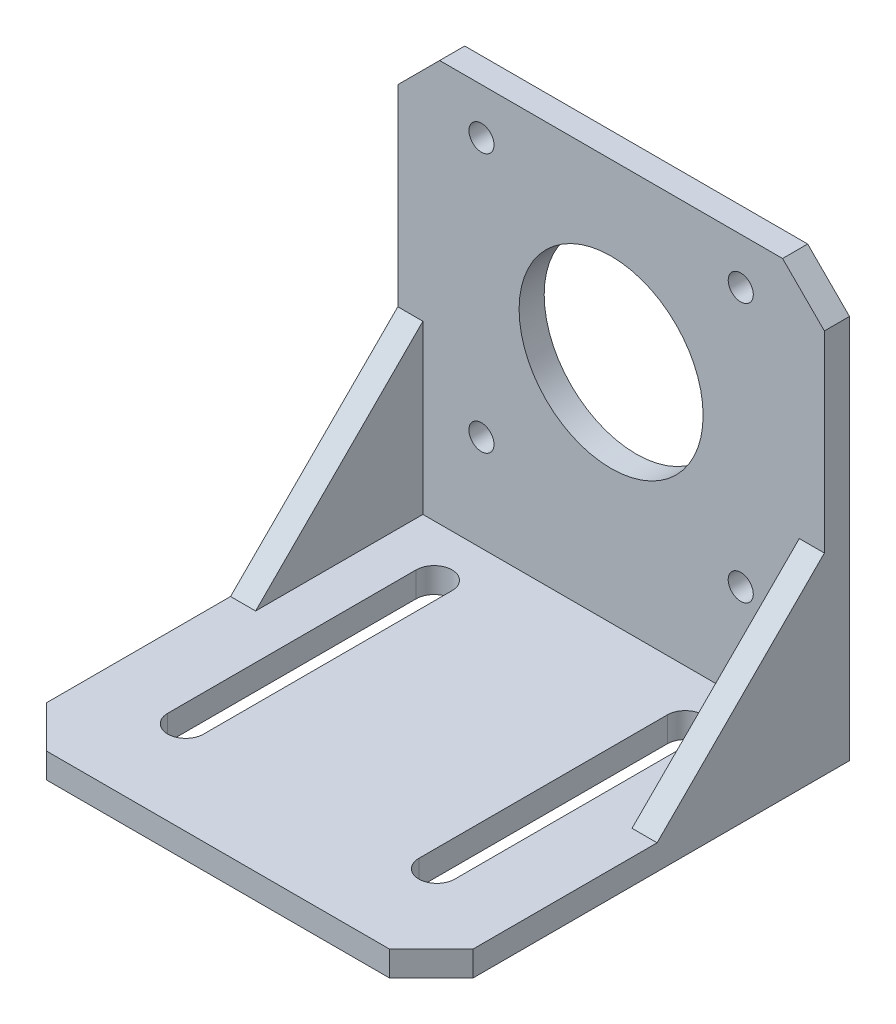
from build123d import *

# Parameters (mm, degrees)
SKETCH1_W           = 51
SKETCH1_H           = 50
BOSS_EXTRUDE1_DEPTH = 3
SKETCH2_W           = 51
SKETCH2_H           = 3
BOSS_EXTRUDE2_DEPTH = 51
SKETCH3_R           = 11
SKETCH3_R_2         = 1.5
CUT_EXTRUDE1_DEPTH  = 4
BOSS_EXTRUDE3_DEPTH = 3
CHAMFER1_SIZE       = 5


with BuildPart() as part:
    # Sketch1 → Boss-Extrude1 (new body)
    with BuildSketch(Plane(origin=(0, 0, 0), x_dir=(1, 0, 0), z_dir=(0, 1, 0))):
        Rectangle(SKETCH1_W, SKETCH1_H)
        with BuildLine():
            Line((-12.865, 15.85), (-12.865, -13.85))
            ThreePointArc((-12.865, -13.85), (-15.015, -16), (-17.165, -13.85))
            Line((-17.165, -13.85), (-17.165, 15.85))
            ThreePointArc((-17.165, 15.85), (-15.015, 18), (-12.865, 15.85))
        make_face(mode=Mode.SUBTRACT)
        with BuildLine():
            Line((12.865, 15.85), (12.865, -13.85))
            ThreePointArc((12.865, -13.85), (15.015, -16), (17.165, -13.85))
            Line((17.165, -13.85), (17.165, 15.85))
            ThreePointArc((17.165, 15.85), (15.015, 18), (12.865, 15.85))
        make_face(mode=Mode.SUBTRACT)
    extrude(amount=BOSS_EXTRUDE1_DEPTH)

    # Sketch2 → Boss-Extrude2 (add)
    with BuildSketch(Plane.XZ):
        with Locations((0, -23.5)):
            Rectangle(SKETCH2_W, SKETCH2_H)
    extrude(amount=-BOSS_EXTRUDE2_DEPTH)

    # Sketch3 → Cut-Extrude1 (cut, through all)
    with BuildSketch(Plane.XY.offset(-22)):
        with Locations((0, 30)):
            Circle(SKETCH3_R)
        with Locations((-15.5, 45.5)):
            Circle(SKETCH3_R_2)
        with Locations((15.5, 45.5)):
            Circle(SKETCH3_R_2)
        with Locations((-15.5, 14.5)):
            Circle(SKETCH3_R_2)
        with Locations((15.5, 14.5)):
            Circle(SKETCH3_R_2)
    extrude(amount=-CUT_EXTRUDE1_DEPTH, mode=Mode.SUBTRACT)

    # Sketch5 → Boss-Extrude3 (add)
    with BuildSketch(Plane.ZY.offset(25.5)):
        Polygon((-22, 23), (-2, 3), (-22, 3), align=None)
    boss_extrude3 = extrude(amount=-BOSS_EXTRUDE3_DEPTH)

    # Mirror1: Boss-Extrude3 across plane
    add(boss_extrude3.mirror(Plane(origin=(0, 0, 0), x_dir=(0, 0, 1), z_dir=(1, 0, 0))))

    # Chamfer1
    chamfer1_edges = [part.edges().sort_by_distance(p)[0] for p in [
        (-25.5, 51, -23.5),
        (25.5, 51, -23.5),
        (25.5, 1.5, 25),
        (-25.5, 1.5, 25),
    ]]
    chamfer(chamfer1_edges, length=CHAMFER1_SIZE)


solid = part.part
